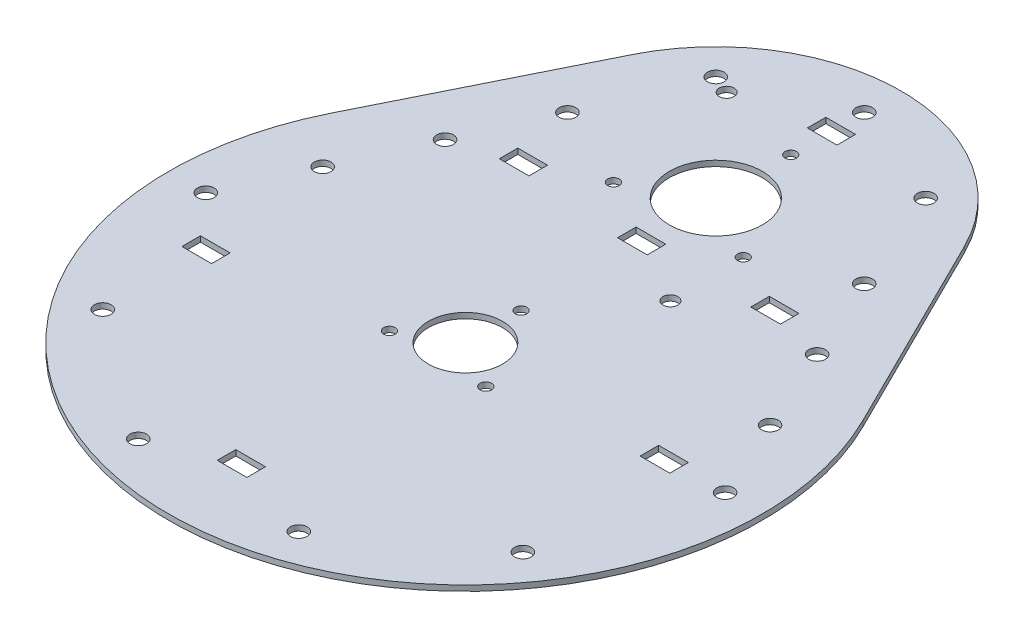
from build123d import *

# Parameters (mm, degrees)
SKETCH1_R           = 10
SKETCH1_R_2         = 1.55
SKETCH1_R_3         = 12.525
SKETCH1_R_4         = 2.25
SKETCH1_R_5         = 2
SKETCH1_W           = 8
SKETCH1_H           = 5
BOSS_EXTRUDE1_DEPTH = 1.5


with BuildPart() as part:
    # Sketch1 → Boss-Extrude1 (new body)
    with BuildSketch(Plane(origin=(0, 0, 0), x_dir=(1, 0, 0), z_dir=(0, 1, 0))):
        with BuildLine():
            Line((44.790320824, 89.722222222), (71.664513318, 35.555555556))
            ThreePointArc((71.664513318, 35.555555556), (0, -80), (-71.664513318, 35.555555556))
            Line((-71.664513318, 35.555555556), (-44.790320824, 89.722222222))
            ThreePointArc((-44.790320824, 89.722222222), (0, 117.5), (44.790320824, 89.722222222))
        make_face()
        Circle(SKETCH1_R, mode=Mode.SUBTRACT)
        with Locations((-12.990381057, -7.5)):
            Circle(SKETCH1_R_2, mode=Mode.SUBTRACT)
        with Locations((12.990381057, -7.5)):
            Circle(SKETCH1_R_2, mode=Mode.SUBTRACT)
        with Locations((0, 15)):
            Circle(SKETCH1_R_2, mode=Mode.SUBTRACT)
        with Locations((0, 67.5)):
            Circle(SKETCH1_R_3, mode=Mode.SUBTRACT)
        with Locations((40, 67.5)):
            Circle(SKETCH1_R_4, mode=Mode.SUBTRACT)
        with Locations((70, 0)):
            Circle(SKETCH1_R_4, mode=Mode.SUBTRACT)
        with Locations((56.631189606, -41.14496766)):
            Circle(SKETCH1_R_4, mode=Mode.SUBTRACT)
        with Locations((21.631189606, -66.573956141)):
            Circle(SKETCH1_R_4, mode=Mode.SUBTRACT)
        with Locations((-21.631189606, -66.573956141)):
            Circle(SKETCH1_R_4, mode=Mode.SUBTRACT)
        with Locations((-56.631189606, -41.14496766)):
            Circle(SKETCH1_R_4, mode=Mode.SUBTRACT)
        with Locations((-70, 0)):
            Circle(SKETCH1_R_4, mode=Mode.SUBTRACT)
        with Locations((28.284271247, 95.784271247)):
            Circle(SKETCH1_R_4, mode=Mode.SUBTRACT)
        with Locations((0, 107.5)):
            Circle(SKETCH1_R_4, mode=Mode.SUBTRACT)
        with Locations((-28.284271247, 95.784271247)):
            Circle(SKETCH1_R_4, mode=Mode.SUBTRACT)
        with Locations((-40, 67.5)):
            Circle(SKETCH1_R_4, mode=Mode.SUBTRACT)
        with Locations((-50.153461651, 44.654711284)):
            Circle(SKETCH1_R_4, mode=Mode.SUBTRACT)
        with Locations((-60.306923303, 21.809422569)):
            Circle(SKETCH1_R_4, mode=Mode.SUBTRACT)
        with Locations((50.153461651, 44.654711284)):
            Circle(SKETCH1_R_4, mode=Mode.SUBTRACT)
        with Locations((60.306923303, 21.809422569)):
            Circle(SKETCH1_R_4, mode=Mode.SUBTRACT)
        with Locations((0, 87.707259422)):
            Circle(SKETCH1_R_2, mode=Mode.SUBTRACT)
        with Locations((-17.5, 57.396370289)):
            Circle(SKETCH1_R_2, mode=Mode.SUBTRACT)
        with Locations((17.5, 57.396370289)):
            Circle(SKETCH1_R_2, mode=Mode.SUBTRACT)
        with Locations((-23.249483938, 93.662215055)):
            Circle(SKETCH1_R_5, mode=Mode.SUBTRACT)
        with Locations((17.859623375, 37.399603775)):
            Circle(SKETCH1_R_5, mode=Mode.SUBTRACT)
        with Locations((0, 47.5)):
            Rectangle(SKETCH1_W, SKETCH1_H, mode=Mode.SUBTRACT)
        with Locations((-1.994503305, -58.420364393)):
            Rectangle(SKETCH1_W, SKETCH1_H, mode=Mode.SUBTRACT)
        with Locations((-34.37581539, 50)):
            Rectangle(SKETCH1_W, SKETCH1_H, mode=Mode.SUBTRACT)
        with Locations((34.136464886, 49.290075758)):
            Rectangle(SKETCH1_W, SKETCH1_H, mode=Mode.SUBTRACT)
        with Locations((54.012994775, -0.420504721)):
            Rectangle(SKETCH1_W, SKETCH1_H, mode=Mode.SUBTRACT)
        with Locations((-56.673760324, -13.260168312)):
            Rectangle(SKETCH1_W, SKETCH1_H, mode=Mode.SUBTRACT)
        with Locations((-0.046638908, 98.711772009)):
            Rectangle(SKETCH1_W, SKETCH1_H, mode=Mode.SUBTRACT)
    extrude(amount=BOSS_EXTRUDE1_DEPTH)


solid = part.part
